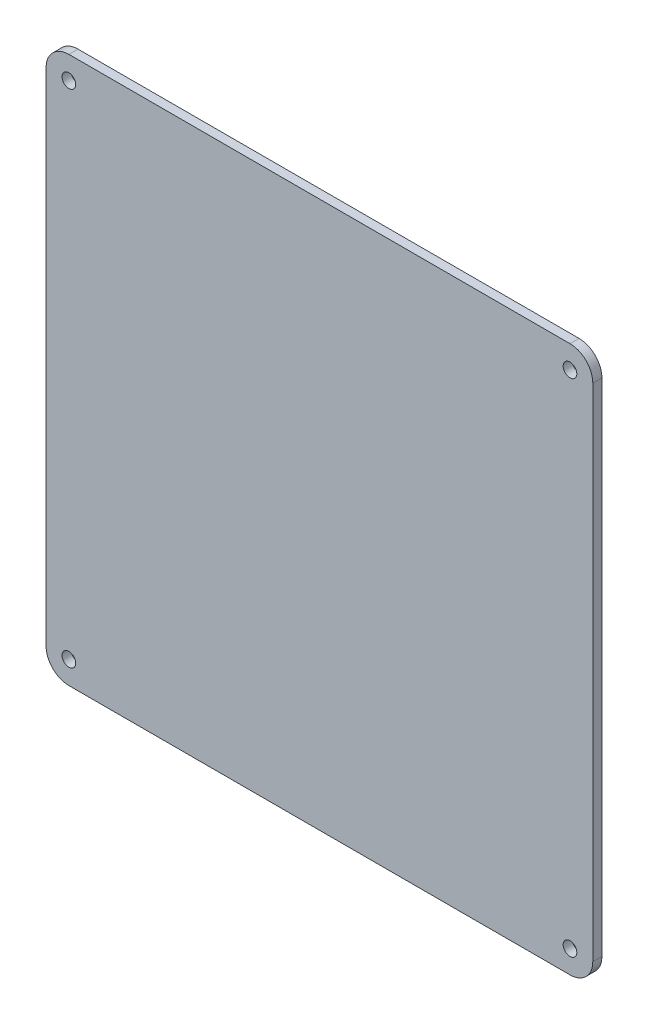
from build123d import *

# Parameters (mm, degrees)
ESBO_O1_R                = 1.5
RESSALTO_EXTRUS_O1_DEPTH = 2


with BuildPart() as part:
    # Esboço1 → Ressalto-extrusão1 (new body)
    with BuildSketch(Plane.XY):
        with BuildLine():
            Line((-55, 60), (55, 60))
            ThreePointArc((55, 60), (58.535533906, 58.535533906), (60, 55))
            Line((60, 55), (60, -55))
            ThreePointArc((60, -55), (58.535533906, -58.535533906), (55, -60))
            Line((55, -60), (-55, -60))
            ThreePointArc((-55, -60), (-58.535533906, -58.535533906), (-60, -55))
            Line((-60, -55), (-60, 55))
            ThreePointArc((-60, 55), (-58.535533906, 58.535533906), (-55, 60))
        make_face()
        with Locations((-55, 55)):
            Circle(ESBO_O1_R, mode=Mode.SUBTRACT)
        with Locations((55, 55)):
            Circle(ESBO_O1_R, mode=Mode.SUBTRACT)
        with Locations((-55, -55)):
            Circle(ESBO_O1_R, mode=Mode.SUBTRACT)
        with Locations((55, -55)):
            Circle(ESBO_O1_R, mode=Mode.SUBTRACT)
    extrude(amount=RESSALTO_EXTRUS_O1_DEPTH)


solid = part.part
